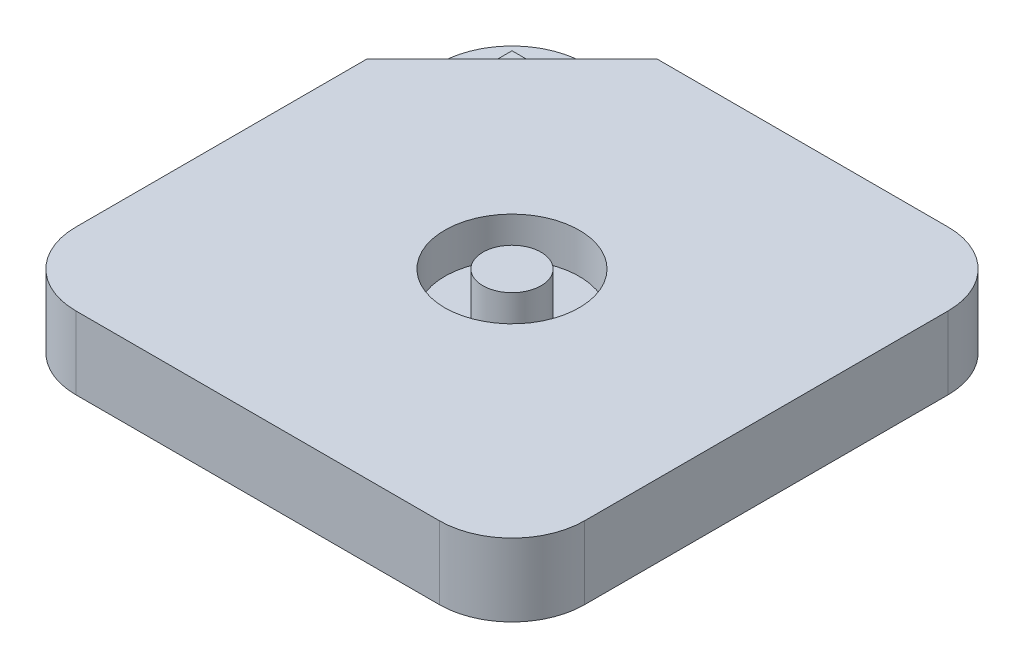
from build123d import *

# Parameters (mm, degrees)
SKETCH_1_W          = 70
SKETCH_1_H          = 70
EXTRUDE_1_DEPTH     = 10
SKETCH_2_R          = 9.25
CUT_EXTRUDE_1_DEPTH = 5.5
SKETCH_3_R          = 4
EXTRUDE_2_DEPTH     = 5.5
CUT_EXTRUDE_2_DEPTH = 5.5
EXTRUDE_3_DEPTH     = 4.5
FILLET_1_R          = 10


with BuildPart() as part:
    # 草图1 → 凸台-拉伸1 (new body)
    with BuildSketch(Plane(origin=(0, 0, 0), x_dir=(1, 0, 0), z_dir=(0, 1, 0))):
        Rectangle(SKETCH_1_W, SKETCH_1_H)
    extrude(amount=EXTRUDE_1_DEPTH)

    # 草图2 → 切除-拉伸1 (cut)
    with BuildSketch(Plane(origin=(0, 10, 0), x_dir=(1, 0, 0), z_dir=(0, 1, 0))):
        Circle(SKETCH_2_R)
    extrude(amount=-CUT_EXTRUDE_1_DEPTH, mode=Mode.SUBTRACT)

    # 草图3 → 凸台-拉伸2 (add)
    with BuildSketch(Plane(origin=(0, 4.5, 0), x_dir=(1, 0, 0), z_dir=(0, 1, 0))):
        Circle(SKETCH_3_R)
    extrude(amount=EXTRUDE_2_DEPTH)

    # 草图4 → 切除-拉伸2 (cut)
    with BuildSketch(Plane(origin=(0, 10, 0), x_dir=(1, 0, 0), z_dir=(0, 1, 0))):
        Polygon((-35, 35), (-15, 35), (-35, 15), align=None)
    extrude(amount=-CUT_EXTRUDE_2_DEPTH, mode=Mode.SUBTRACT)

    # 草图5 → 凸台-拉伸3 (add)
    with BuildSketch(Plane(origin=(0, 4.5, 0), x_dir=(1, 0, 0), z_dir=(0, 1, 0))):
        Polygon((-23, 27), (-27, 27), (-27, 23), align=None)
    extrude(amount=EXTRUDE_3_DEPTH)

    # 圆角1
    fillet_1_edges = [part.edges().sort_by_distance(p)[0] for p in [
        (-35, 2.25, -35),
        (35, 5, 35),
        (-35, 5, 35),
        (35, 5, -35),
    ]]
    fillet(fillet_1_edges, radius=FILLET_1_R)


solid = part.part
